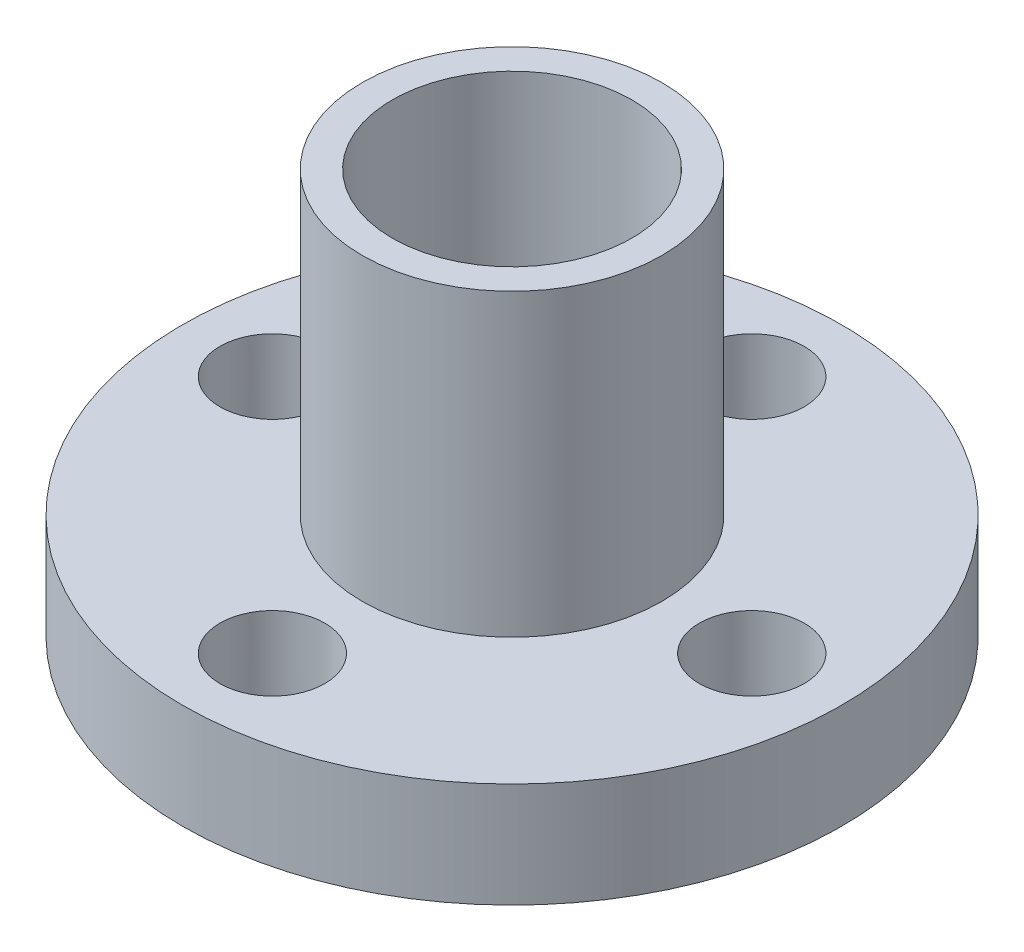
from build123d import *

# Parameters (mm, degrees)
SKETCH_1_R          = 5
EXTRUDE_1_DEPTH     = 1.5
SKETCH_2_R          = 11
EXTRUDE_2_DEPTH     = 3.5
SKETCH_3_R          = 5
EXTRUDE_3_DEPTH     = 10
SKETCH_4_R          = 4
CUT_EXTRUDE_1_DEPTH = 16
SKETCH_5_R          = 1.75
CUT_EXTRUDE_2_DEPTH = 16


with BuildPart() as part:
    # 草图1 → 凸台-拉伸1 (new body)
    with BuildSketch(Plane(origin=(0, 0, 0), x_dir=(1, 0, 0), z_dir=(0, 1, 0))):
        Circle(SKETCH_1_R)
    extrude(amount=EXTRUDE_1_DEPTH)

    # 草图2 → 凸台-拉伸2 (add)
    with BuildSketch(Plane(origin=(0, 1.5, 0), x_dir=(1, 0, 0), z_dir=(0, 1, 0))):
        Circle(SKETCH_2_R)
    extrude(amount=EXTRUDE_2_DEPTH)

    # 草图3 → 凸台-拉伸3 (add)
    with BuildSketch(Plane(origin=(0, 5, 0), x_dir=(1, 0, 0), z_dir=(0, 1, 0))):
        Circle(SKETCH_3_R)
    extrude(amount=EXTRUDE_3_DEPTH)

    # 草图4 → 切除-拉伸1 (cut)
    with BuildSketch(Plane.XZ):
        Circle(SKETCH_4_R)
    extrude(amount=-CUT_EXTRUDE_1_DEPTH, mode=Mode.SUBTRACT)

    # 草图5 → 切除-拉伸2 (cut)
    with BuildSketch(Plane.XZ.offset(-1.5)):
        with Locations((8, 0)):
            Circle(SKETCH_5_R)
        with Locations((0, -8)):
            Circle(SKETCH_5_R)
        with Locations((-8, 0)):
            Circle(SKETCH_5_R)
        with Locations((0, 8)):
            Circle(SKETCH_5_R)
    extrude(amount=-CUT_EXTRUDE_2_DEPTH, mode=Mode.SUBTRACT)


solid = part.part
